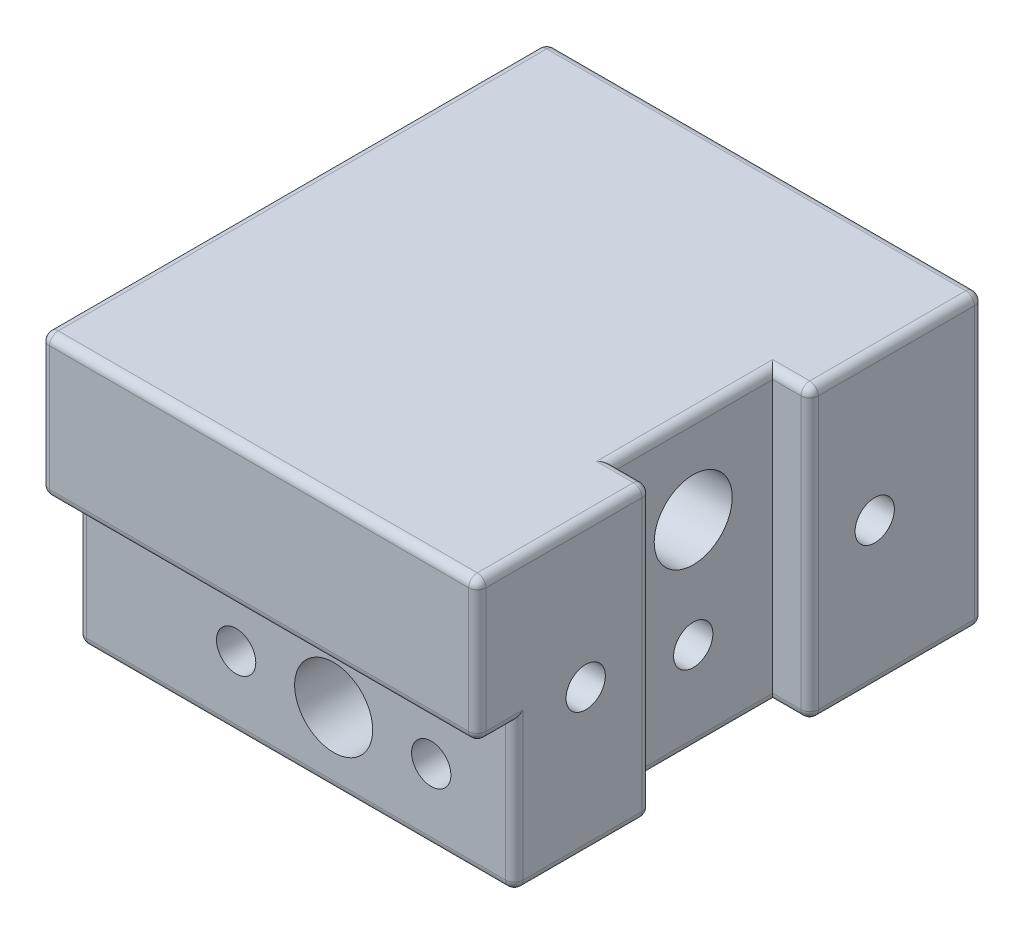
from build123d import *

# Parameters (mm, degrees)
SKETCH1_W           = 38.354
SKETCH1_H           = 44.45
BOSS_EXTRUDE1_DEPTH = 25.4
SKETCH2_R           = 3.429
CUT_EXTRUDE1_DEPTH  = 44.45
SKETCH3_R           = 1.7272
CUT_EXTRUDE2_DEPTH  = 12.7
SKETCH5_R           = 1.7272
CUT_EXTRUDE4_DEPTH  = 12.7
SKETCH6_R           = 3.429
CUT_EXTRUDE5_DEPTH  = 38.354
SKETCH7_R           = 1.7272
CUT_EXTRUDE6_DEPTH  = 9.525
SKETCH11_W          = 38.354
SKETCH11_H          = 12.954
CUT_EXTRUDE9_DEPTH  = 3.2512
CUT_EXTRUDE7_START  = -7.62
SKETCH8_R           = 1.7272
CUT_EXTRUDE7_DEPTH  = 7.62
BOSS_EXTRUDE2_START = 2.54
SKETCH9_R           = 1.7272
SKETCH9_R_2         = 3.429
BOSS_EXTRUDE2_DEPTH = 2.54
SKETCH12_W          = 13.97
SKETCH12_H          = 25.4
CUT_EXTRUDE10_DEPTH = 3.2512
SKETCH13_R          = 1.7272
CUT_EXTRUDE11_DEPTH = 6.35
FILLET1_R           = 0.762


with BuildPart() as part:
    # Sketch1 → Boss-Extrude1 (new body)
    with BuildSketch(Plane(origin=(0, 0, 0), x_dir=(1, 0, 0), z_dir=(0, 1, 0))):
        with Locations((19.177, 22.225)):
            Rectangle(SKETCH1_W, SKETCH1_H)
    extrude(amount=BOSS_EXTRUDE1_DEPTH)

    # Sketch2 → Cut-Extrude1 (cut)
    with BuildSketch(Plane.XY):
        with Locations((22.479, 6.35)):
            Circle(SKETCH2_R)
    extrude(amount=-CUT_EXTRUDE1_DEPTH, mode=Mode.SUBTRACT)

    # Sketch3 → Cut-Extrude2 (cut)
    with BuildSketch(Plane(origin=(38.354, 0, 0), x_dir=(0, 0, -1), z_dir=(1, 0, 0))):
        with Locations((9.525, 12.7)):
            Circle(SKETCH3_R)
        with Locations((34.925, 12.7)):
            Circle(SKETCH3_R)
    extrude(amount=-CUT_EXTRUDE2_DEPTH, mode=Mode.SUBTRACT)

    # Sketch5 → Cut-Extrude4 (cut)
    with BuildSketch(Plane.ZY):
        with Locations((-31.75, 6.35)):
            Circle(SKETCH5_R)
        with Locations((-12.7, 6.35)):
            Circle(SKETCH5_R)
    extrude(amount=-CUT_EXTRUDE4_DEPTH, mode=Mode.SUBTRACT)

    # Sketch6 → Cut-Extrude5 (cut)
    with BuildSketch(Plane.ZY):
        with Locations((-22.225, 17.4625)):
            Circle(SKETCH6_R)
    extrude(amount=-CUT_EXTRUDE5_DEPTH, mode=Mode.SUBTRACT)

    # Sketch7 → Cut-Extrude6 (cut)
    with BuildSketch(Plane(origin=(0, 0, -44.45), x_dir=(-1, 0, 0), z_dir=(0, 0, -1))):
        with Locations((-31.0515, 6.35)):
            Circle(SKETCH7_R)
        with Locations((-13.9065, 6.35)):
            Circle(SKETCH7_R)
    extrude(amount=-CUT_EXTRUDE6_DEPTH, mode=Mode.SUBTRACT)

    # Sketch11 → Cut-Extrude9 (cut)
    with BuildSketch(Plane.XY):
        with Locations((19.177, 6.477)):
            Rectangle(SKETCH11_W, SKETCH11_H)
    extrude(amount=-CUT_EXTRUDE9_DEPTH, mode=Mode.SUBTRACT)

    # Sketch8 → Cut-Extrude7 (cut)
    with BuildSketch(Plane.XY.offset(-3.2512).offset(CUT_EXTRUDE7_START)):
        with Locations(Location((13.9065, 6.35, 0), (0, 0, 180))):
            Circle(SKETCH8_R)
        with Locations(Location((31.0515, 6.35, 0), (0, 0, 180))):
            Circle(SKETCH8_R)
    extrude(amount=CUT_EXTRUDE7_DEPTH, mode=Mode.SUBTRACT)

    # Sketch9 → Boss-Extrude2 (add)
    with BuildSketch(Plane(origin=(0, 0, -44.45), x_dir=(-1, 0, 0), z_dir=(0, 0, -1)).offset(BOSS_EXTRUDE2_START)):
        with BuildLine():
            Line((-32.545062003, 0), (-12.412937997, 0))
            ThreePointArc((-12.412937997, 0), (-22.479, 18.251600911), (-32.545062003, 0))
        make_face()
        with Locations(Location((-31.0515, 6.35, 0), (0, 0, 180))):
            Circle(SKETCH9_R, mode=Mode.SUBTRACT)
        with Locations(Location((-13.9065, 6.35, 0), (0, 0, 180))):
            Circle(SKETCH9_R, mode=Mode.SUBTRACT)
        with Locations(Location((-22.479, 6.35, 0), (0, 0, 180))):
            Circle(SKETCH9_R_2, mode=Mode.SUBTRACT)
    extrude(amount=-BOSS_EXTRUDE2_DEPTH)

    # Sketch12 → Cut-Extrude10 (cut)
    with BuildSketch(Plane(origin=(38.354, 0, 0), x_dir=(0, 0, -1), z_dir=(1, 0, 0))):
        with Locations((22.225, 12.7)):
            Rectangle(SKETCH12_W, SKETCH12_H)
    extrude(amount=-CUT_EXTRUDE10_DEPTH, mode=Mode.SUBTRACT)

    # Sketch13 → Cut-Extrude11 (cut)
    with BuildSketch(Plane(origin=(35.1028, 0, 0), x_dir=(0, 0, -1), z_dir=(1, 0, 0))):
        with Locations((22.225, 7.9375)):
            Circle(SKETCH13_R)
    extrude(amount=-CUT_EXTRUDE11_DEPTH, mode=Mode.SUBTRACT)

    # Fillet1
    fillet1_edges = [part.edges().sort_by_distance(p)[0] for p in [
        (38.354, 25.4, -7.62),
        (19.177, 25.4, -44.45),
        (0, 25.4, -22.225),
        (35.449531001, 0, -44.45),
        (38.354, 0, -9.2456),
        (19.177, 12.954, 0),
        (0, 6.477, -3.2512),
        (0, 12.954, -1.6256),
        (38.354, 6.477, -3.2512),
        (38.354, 12.954, -1.6256),
        (19.177, 0, -3.2512),
        (0, 0, -23.8506),
        (19.177, 25.4, 0),
        (6.206468999, 0, -44.45),
        (0, 12.7, -44.45),
        (38.354, 12.7, -44.45),
        (38.354, 19.177, 0),
        (12.412937997, 0, -45.72),
        (32.545062003, 0, -45.72),
        (0, 19.177, 0),
        (38.354, 25.4, -36.83),
        (38.354, 0, -36.83),
        (38.354, 12.7, -15.24),
        (38.354, 12.7, -29.21),
        (36.7284, 0, -15.24),
        (35.1028, 25.4, -22.225),
        (36.7284, 25.4, -15.24),
        (36.7284, 25.4, -29.21),
        (35.1028, 0, -22.225),
        (36.7284, 0, -29.21),
    ]]
    fillet(fillet1_edges, radius=FILLET1_R)


solid = part.part
